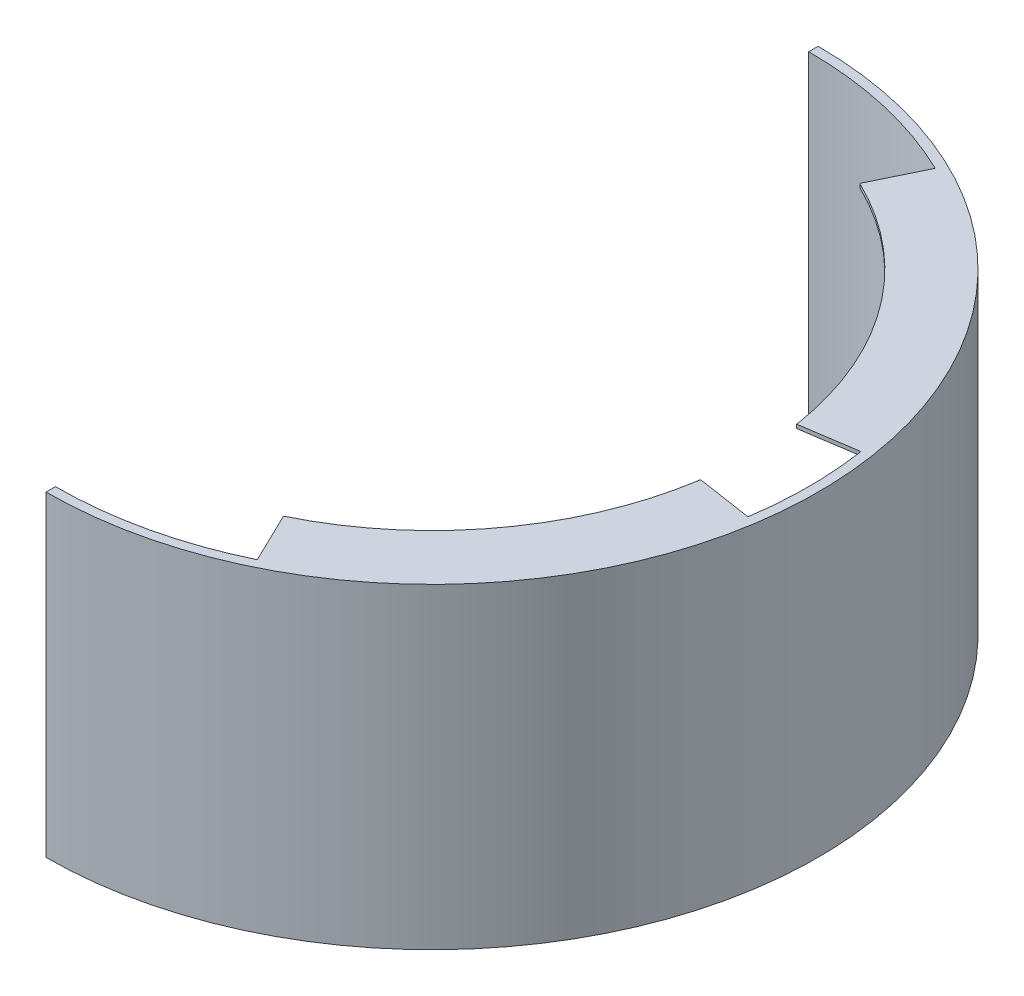
from build123d import *

# Parameters (mm, degrees)
BOSS_EXTRUDE1_DEPTH = 168
BOSS_EXTRUDE2_DEPTH = 2


with BuildPart() as part:
    # Sketch1 → Boss-Extrude1 (new body)
    with BuildSketch(Plane(origin=(0, 0, 0), x_dir=(1, 0, 0), z_dir=(0, 1, 0))):
        with BuildLine():
            Line((0, 205), (0, 200))
            ThreePointArc((0, 200), (200, 0), (0, -200))
            Line((0, -200), (0, -205))
            ThreePointArc((0, -205), (205, 0), (0, 205))
        make_face()
    extrude(amount=BOSS_EXTRUDE1_DEPTH)

    # Sketch2 → Boss-Extrude2 (add)
    with BuildSketch(Plane(origin=(0, 0, 0), x_dir=(1, 0, 0), z_dir=(0, 1, 0))):
        with BuildLine():
            Line((87.177978871, -180), (74.10128204, -153))
            ThreePointArc((74.10128204, -153), (136.845155159, -100.863291189), (168.076619433, -25.5))
            Line((168.076619433, -25.5), (197.737199333, -30))
            ThreePointArc((197.737199333, -30), (160.994300187, -118.662695517), (87.177978871, -180))
        make_face()
        with BuildLine():
            Line((197.737199333, 30), (168.076619433, 25.5))
            ThreePointArc((168.076619433, 25.5), (136.845155159, 100.863291189), (74.10128204, 153))
            Line((74.10128204, 153), (87.177978871, 180))
            ThreePointArc((87.177978871, 180), (160.994300187, 118.662695517), (197.737199333, 30))
        make_face()
    boss_extrude2 = extrude(amount=BOSS_EXTRUDE2_DEPTH)

    # Mirror2: Boss-Extrude2 across plane
    add(boss_extrude2.mirror(Plane.ZX.offset(84)))


solid = part.part
